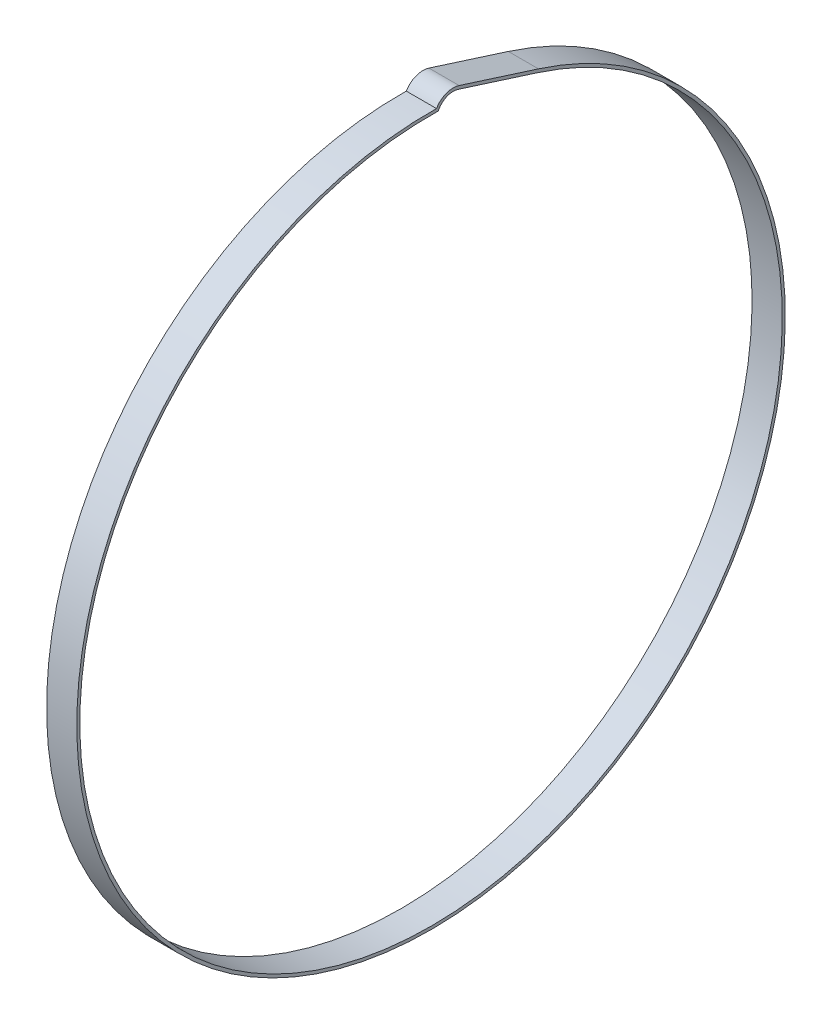
from build123d import *

# Parameters (mm, degrees)
BOSS_EXTRUDE1_DEPTH = 12.7


with BuildPart() as part:
    # Sketch1 → Boss-Extrude1 (new body)
    with BuildSketch(Plane(origin=(0, 0, 0), x_dir=(0, 0, -1), z_dir=(1, 0, 0))):
        with BuildLine():
            Line((45.172537999, 141.957038049), (11.797012955, 152.577555313))
            ThreePointArc((11.797012955, 152.577555313), (6.406042935, 152.427160627), (2.28061581, 148.95354186))
            ThreePointArc((2.28061581, 148.95354186), (-23.983081912, -147.027788608), (45.172537999, 141.957038049))
        make_face()
        with BuildLine():
            Line((44.787435373, 140.746833121), (11.411910329, 151.367350385))
            ThreePointArc((11.411910329, 151.367350385), (6.525607749, 151.103719143), (3.039474855, 147.669722671))
            ThreePointArc((3.039474855, 147.669722671), (-24.162676495, -145.711188539), (44.787435373, 140.746833121))
        make_face(mode=Mode.SUBTRACT)
    extrude(amount=BOSS_EXTRUDE1_DEPTH)


solid = part.part
